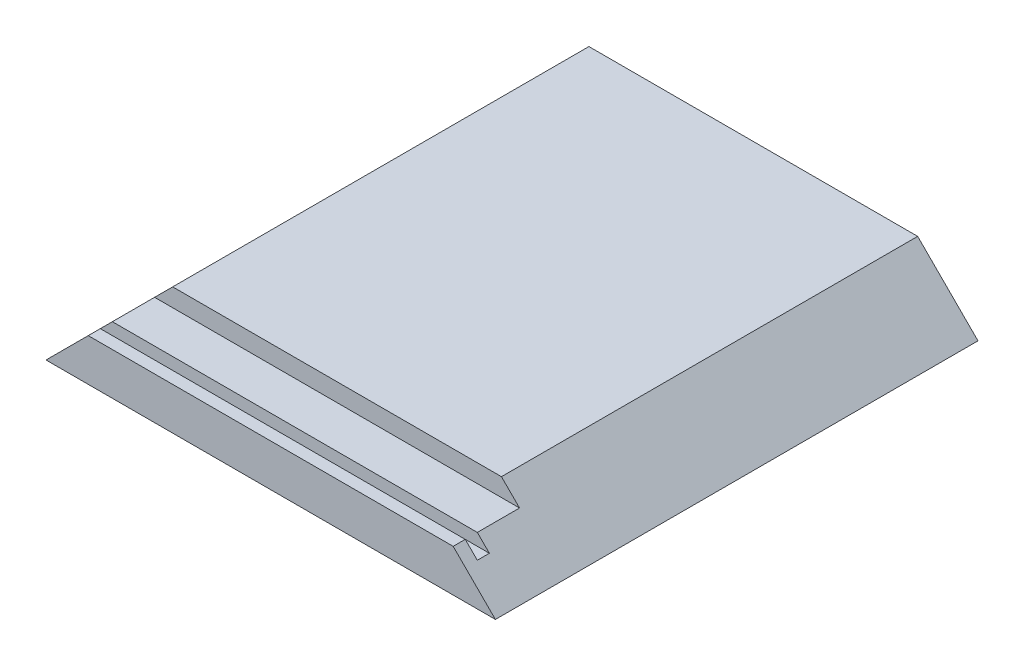
from build123d import *

# Parameters (mm, degrees)
SKETCH1_W           = 74.5
SKETCH1_H           = 80
BOSS_EXTRUDE1_DEPTH = 10
SKETCH2_W           = 11
SKETCH2_H           = 3
CUT_EXTRUDE1_DEPTH  = 75.5
SKETCH3_W           = 2
SKETCH3_H           = 2
CUT_EXTRUDE2_DEPTH  = 75.5
CUT_EXTRUDE4_DEPTH  = 81


with BuildPart() as part:
    # Sketch1 → Boss-Extrude1 (new body)
    with BuildSketch(Plane(origin=(0, 0, 0), x_dir=(1, 0, 0), z_dir=(0, 1, 0))):
        Rectangle(SKETCH1_W, SKETCH1_H)
    extrude(amount=BOSS_EXTRUDE1_DEPTH)

    # Sketch2 → Cut-Extrude1 (cut, through all)
    with BuildSketch(Plane.ZY.offset(37.25)):
        with Locations((34.5, 8.5)):
            Rectangle(SKETCH2_W, SKETCH2_H)
    extrude(amount=-CUT_EXTRUDE1_DEPTH, mode=Mode.SUBTRACT)

    # Sketch3 → Cut-Extrude2 (cut, through all)
    with BuildSketch(Plane.ZY.offset(37.25)):
        with Locations((37, 6)):
            Rectangle(SKETCH3_W, SKETCH3_H)
    extrude(amount=-CUT_EXTRUDE2_DEPTH, mode=Mode.SUBTRACT)

    # Sketch4 → Cut-Extrude4 (cut, through all)
    with BuildSketch(Plane(origin=(0, 0, -40), x_dir=(-1, 0, 0), z_dir=(0, 0, -1))):
        Polygon((-37.25, 0), (-27.25, 10), (-37.25, 10), align=None)
        Polygon((37.25, 10), (37.25, 0), (27.25, 10), align=None)
    extrude(amount=-CUT_EXTRUDE4_DEPTH, mode=Mode.SUBTRACT)


solid = part.part
